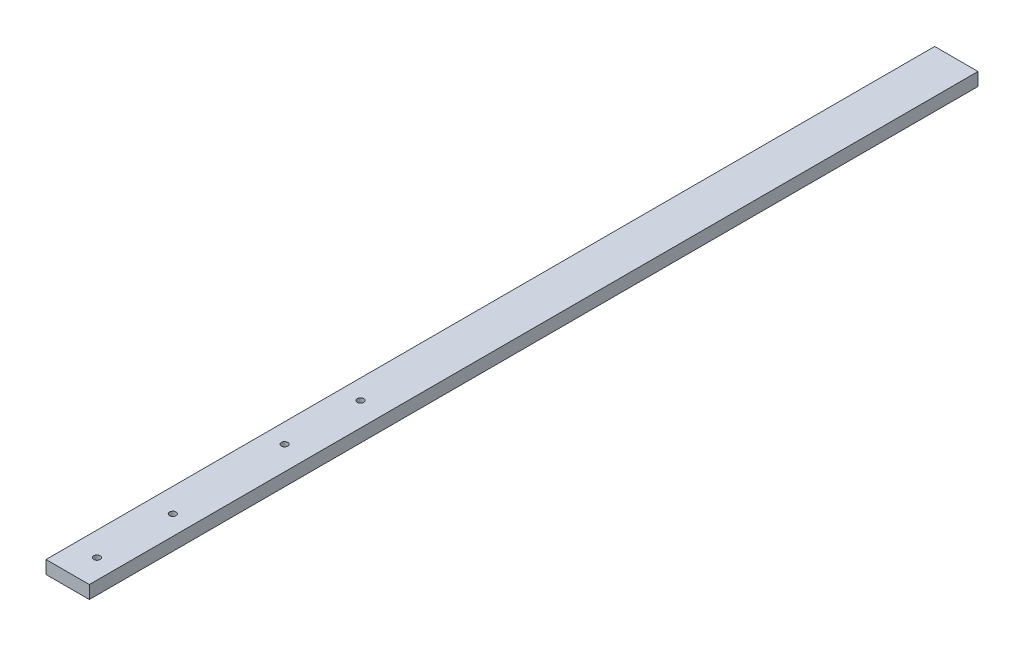
from build123d import *

# Parameters (mm, degrees)
SKETCH1_W           = 20
SKETCH1_H           = 410
BOSS_EXTRUDE1_DEPTH = 6
SKETCH2_R           = 1.5
CUT_EXTRUDE1_DEPTH  = 7


with BuildPart() as part:
    # Sketch1 → Boss-Extrude1 (new body)
    with BuildSketch(Plane(origin=(0, 0, 0), x_dir=(1, 0, 0), z_dir=(0, 1, 0))):
        Rectangle(SKETCH1_W, SKETCH1_H)
    extrude(amount=BOSS_EXTRUDE1_DEPTH)

    # Sketch2 → Cut-Extrude1 (cut, through all)
    with BuildSketch(Plane(origin=(0, 6, 0), x_dir=(1, 0, 0), z_dir=(0, 1, 0))):
        with Locations((1, -192.5)):
            Circle(SKETCH2_R)
        with Locations((1, -157.5)):
            Circle(SKETCH2_R)
        with Locations((-1, -103.9)):
            Circle(SKETCH2_R)
        with Locations((-1, -68.9)):
            Circle(SKETCH2_R)
    extrude(amount=-CUT_EXTRUDE1_DEPTH, mode=Mode.SUBTRACT)


solid = part.part
